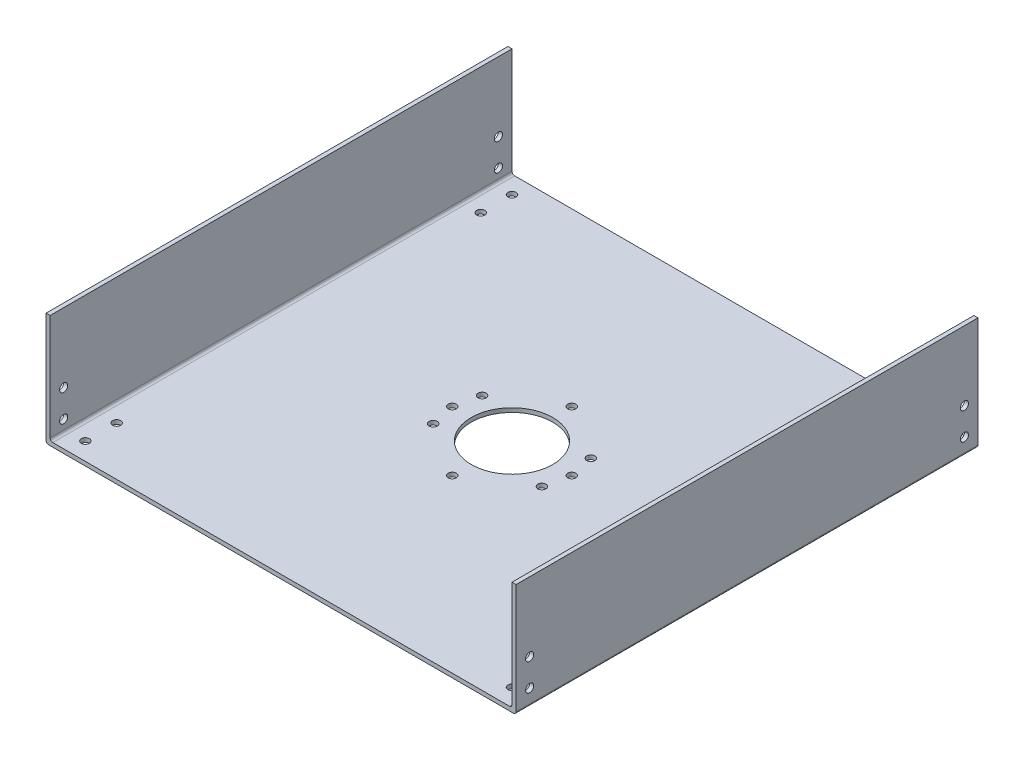
from build123d import *

# Parameters (mm, degrees)
SKETCH2_W               = 170
SKETCH2_H               = 170
SKETCH2_R               = 1.5
BOSS_EXTRUDE1_DEPTH     = 1.5
CUT_EXTRUDE1_DEPTH      = 5
CUT_EXTRUDE1_DEPTH_BACK = 5
SKETCH5_R               = 15
CUT_EXTRUDE2_DEPTH      = 5
CUT_EXTRUDE2_DEPTH_BACK = 5
SKETCH6_R               = 1.5
CUT_EXTRUDE3_DEPTH      = 5
CUT_EXTRUDE3_DEPTH_BACK = 5
SKETCH7_R               = 1.5
CUT_EXTRUDE4_DEPTH      = 10
CUT_EXTRUDE4_DEPTH_BACK = 10
SKETCH8_R               = 1.5
SKETCH9_W               = 170
SKETCH9_H               = 41.5
BOSS_EXTRUDE2_DEPTH     = 1.5
FILLET2_R               = 1
FILLET3_R               = 1
SKETCH10_W              = 170
SKETCH10_H              = 41.5
BOSS_EXTRUDE3_DEPTH     = 1.5
FILLET4_R               = 1
FILLET5_R               = 1
CUT_EXTRUDE6_DEPTH      = 10000
CUT_EXTRUDE6_DEPTH_BACK = 10000
SKETCH15_R              = 1.5


with BuildPart() as part:
    # Sketch2 → Boss-Extrude1 (new body)
    with BuildSketch(Plane(origin=(0, 0, 0), x_dir=(1, 0, 0), z_dir=(0, 1, 0))):
        with Locations((85, 85)):
            Rectangle(SKETCH2_W, SKETCH2_H)
        with Locations((63, 85)):
            Circle(SKETCH2_R, mode=Mode.SUBTRACT)
        with Locations((85, 63)):
            Circle(SKETCH2_R, mode=Mode.SUBTRACT)
        with Locations((85, 107)):
            Circle(SKETCH2_R, mode=Mode.SUBTRACT)
        with Locations((107, 85)):
            Circle(SKETCH2_R, mode=Mode.SUBTRACT)
    extrude(amount=BOSS_EXTRUDE1_DEPTH)

    # Sketch5 → Cut-Extrude1 (cut, two sides: drawn at the far end of the back side and taken through both)
    with BuildSketch(Plane(origin=(0, 1.5, 0), x_dir=(1, 0, 0), z_dir=(0, 1, 0)).offset(-CUT_EXTRUDE1_DEPTH_BACK)):
        with Locations((85, 85)):
            Circle(SKETCH5_R)
    extrude(amount=CUT_EXTRUDE1_DEPTH + CUT_EXTRUDE1_DEPTH_BACK, mode=Mode.SUBTRACT)

    # Sketch6 → Cut-Extrude2 (cut, two sides: drawn at the far end of the back side and taken through both)
    with BuildSketch(Plane(origin=(0, 1.5, 0), x_dir=(1, 0, 0), z_dir=(0, 1, 0)).offset(-CUT_EXTRUDE2_DEPTH_BACK)):
        with Locations((65, 94)):
            Circle(SKETCH6_R)
        with Locations((65, 76)):
            Circle(SKETCH6_R)
        with Locations((105, 76)):
            Circle(SKETCH6_R)
        with Locations((105, 94)):
            Circle(SKETCH6_R)
    extrude(amount=CUT_EXTRUDE2_DEPTH + CUT_EXTRUDE2_DEPTH_BACK, mode=Mode.SUBTRACT)

    # Sketch7 → Cut-Extrude3 (cut, two sides: drawn at the far end of the back side and taken through both)
    with BuildSketch(Plane(origin=(0, 1.5, 0), x_dir=(1, 0, 0), z_dir=(0, 1, 0)).offset(-CUT_EXTRUDE3_DEPTH_BACK)):
        with Locations((6.5, 163.5)):
            Circle(SKETCH7_R)
        with Locations((163.5, 163.5)):
            Circle(SKETCH7_R)
        with Locations((163.5, 6.5)):
            Circle(SKETCH7_R)
        with Locations((6.5, 6.5)):
            Circle(SKETCH7_R)
    extrude(amount=CUT_EXTRUDE3_DEPTH + CUT_EXTRUDE3_DEPTH_BACK, mode=Mode.SUBTRACT)

    # Sketch8 → Cut-Extrude4 (cut, two sides: drawn at the far end of the back side and taken through both)
    with BuildSketch(Plane(origin=(0, 1.5, 0), x_dir=(1, 0, 0), z_dir=(0, 1, 0)).offset(-CUT_EXTRUDE4_DEPTH_BACK)):
        with Locations((163.5, 18)):
            Circle(SKETCH8_R)
        with Locations((163.5, 152)):
            Circle(SKETCH8_R)
        with Locations((6.5, 152)):
            Circle(SKETCH8_R)
        with Locations((6.5, 18)):
            Circle(SKETCH8_R)
    extrude(amount=CUT_EXTRUDE4_DEPTH + CUT_EXTRUDE4_DEPTH_BACK, mode=Mode.SUBTRACT)

    # Sketch9 → Boss-Extrude2 (add)
    with BuildSketch(Plane(origin=(170, 0, 0), x_dir=(0, 0, -1), z_dir=(1, 0, 0))):
        with Locations((85, 20.75)):
            Rectangle(SKETCH9_W, SKETCH9_H)
    extrude(amount=BOSS_EXTRUDE2_DEPTH)

    # Fillet2
    fillet2_edges = [part.edges().sort_by_distance(p)[0] for p in [
        (170, 1.5, -85),
    ]]
    fillet(fillet2_edges, radius=FILLET2_R)

    # Fillet3
    fillet3_edges = [part.edges().sort_by_distance(p)[0] for p in [
        (171.5, 0, -85),
    ]]
    fillet(fillet3_edges, radius=FILLET3_R)

    # Sketch10 → Boss-Extrude3 (add)
    with BuildSketch(Plane.ZY):
        with Locations((-85, 20.75)):
            Rectangle(SKETCH10_W, SKETCH10_H)
    extrude(amount=BOSS_EXTRUDE3_DEPTH)

    # Fillet4
    fillet4_edges = [part.edges().sort_by_distance(p)[0] for p in [
        (0, 1.5, -85),
    ]]
    fillet(fillet4_edges, radius=FILLET4_R)

    # Fillet5
    fillet5_edges = [part.edges().sort_by_distance(p)[0] for p in [
        (-1.5, 0, -85),
    ]]
    fillet(fillet5_edges, radius=FILLET5_R)

    # Sketch15 → Cut-Extrude6 (cut, two sides: drawn at the far end of the back side and taken through both)
    with BuildSketch(Plane.ZY.offset(1.5).offset(-CUT_EXTRUDE6_DEPTH_BACK)):
        with Locations((-165, 16)):
            Circle(SKETCH15_R)
        with Locations((-165, 6)):
            Circle(SKETCH15_R)
        with Locations((-5, 16)):
            Circle(SKETCH15_R)
        with Locations((-5, 6)):
            Circle(SKETCH15_R)
    extrude(amount=CUT_EXTRUDE6_DEPTH + CUT_EXTRUDE6_DEPTH_BACK, mode=Mode.SUBTRACT)


solid = part.part
